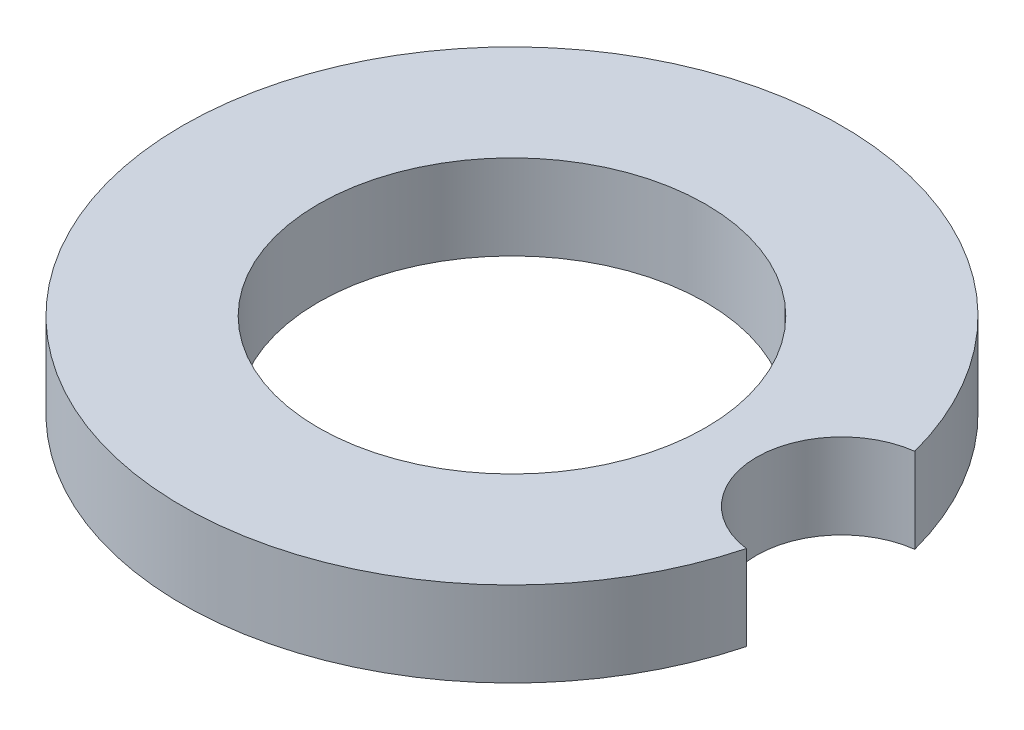
from build123d import *

# Parameters (mm, degrees)
SKETCH1_R           = 49.276
BOSS_EXTRUDE1_DEPTH = 12.7
SKETCH1_10_R        = 28.952599956
CUT_EXTRUDE2_DEPTH  = 71.834584434
SKETCH2_R           = 12.7
CUT_EXTRUDE3_DEPTH  = 71.834584434


with BuildPart() as part:
    # Sketch1 → Boss-Extrude1 (new body)
    with BuildSketch(Plane(origin=(0, 0, 0), x_dir=(1, 0, 0), z_dir=(0, 1, 0))):
        Circle(SKETCH1_R)
    extrude(amount=BOSS_EXTRUDE1_DEPTH)

    # Sketch1_10 → Cut-Extrude2 (cut, through all)
    with BuildSketch(Plane(origin=(0, 0, 0), x_dir=(1, 0, 0), z_dir=(0, 1, 0))):
        Circle(SKETCH1_10_R)
    extrude(amount=CUT_EXTRUDE2_DEPTH, mode=Mode.SUBTRACT)

    # Sketch2 → Cut-Extrude3 (cut, through all)
    with BuildSketch(Plane(origin=(0, 12.7, 0), x_dir=(1, 0, 0), z_dir=(0, 1, 0))):
        with Locations((49.276, 0)):
            Circle(SKETCH2_R)
    extrude(amount=-CUT_EXTRUDE3_DEPTH, mode=Mode.SUBTRACT)


solid = part.part
